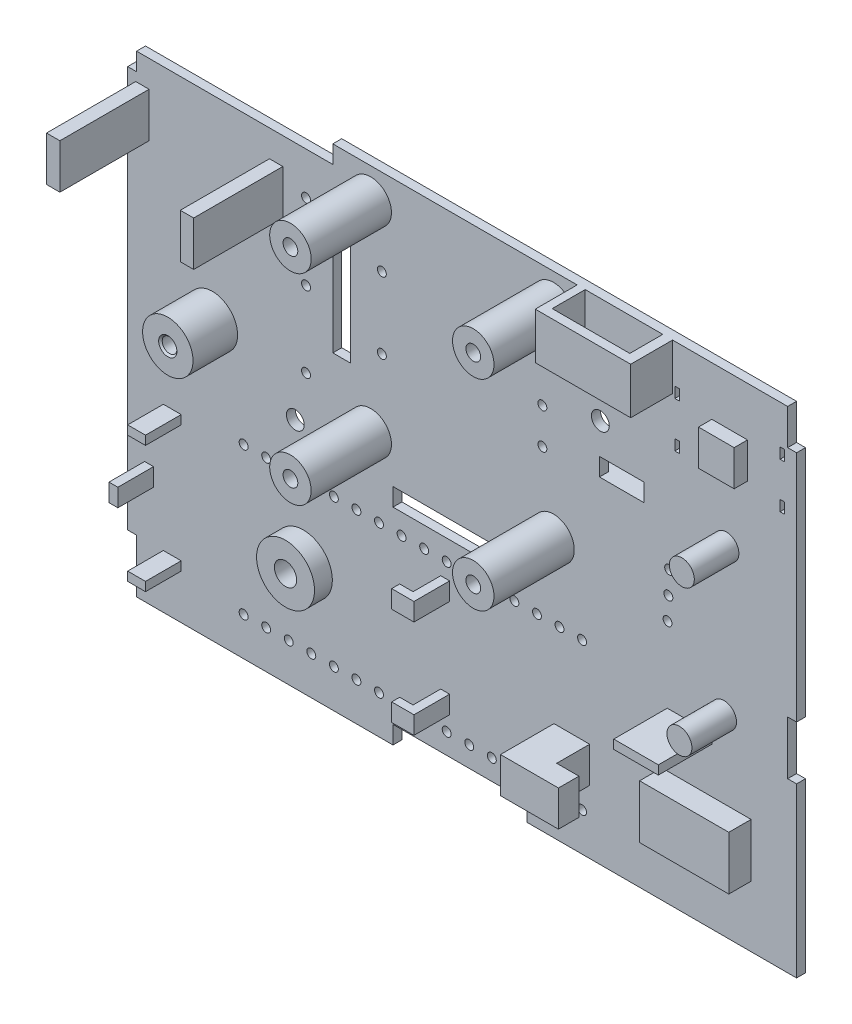
from build123d import *

# Parameters (mm, degrees)
SKETCH_1_W             = 75
SKETCH_1_H             = 55
EXTRUDE_1_DEPTH        = 1
SKETCH_2_W             = 9.7
SKETCH_2_H             = 1.5
EXTRUDE_2_DEPTH        = 7.1
CUT_EXTRUDE_1_REACH    = 20.9
SKETCH_4_W             = 1
SKETCH_4_H             = 1
CUT_EXTRUDE_2_REACH    = 3
SKETCH_5_W             = 5
SKETCH_5_H             = 2
DH11_1_START           = -1
SKETCH_9_R             = 2.825
SKETCH_9_R_2           = 0.825
DH11_1_DEPTH           = 5
SKETCH_36_W            = 1.5
SKETCH_36_H            = 5
DH11_11_DEPTH          = 10
HD11_3_SIZE            = 0.2
SKETCH_13_W            = 0.5
SKETCH_13_H            = 1.2
CUT_EXTRUDE_3_DEPTH    = 1
SKETCH_35_W            = 4
SKETCH_35_H            = 4
EXTRUDE_10_DEPTH       = 2.5
EXTRUDE_START          = -1
SKETCH_18_R            = 3.25
SKETCH_18_R_2          = 1.25
EXTRUDE_9_DEPTH        = 2
SKETCH_38_W            = 1
SKETCH_38_H            = 2
SKETCH_38_W_2          = 2
SKETCH_38_H_2          = 1
EXTRUDE_12_DEPTH       = 4
SKETCH_20_W            = 10.7
SKETCH_20_H            = 5.2
EXTRUDE_6_DEPTH        = 4.7
SKETCH_37_W            = 8.7
SKETCH_37_H            = 3.7
CUT_EXTRUDE_1_10_DEPTH = 4
SKETCH_34_W            = 0.7
SKETCH_34_H            = 0.5
CUT_EXTRUDE_10_DEPTH   = 1.2
SKETCH_28_R            = 1.4
EXTRUDE_11_DEPTH       = 5
SKETCH_19_R            = 0.5
CUT_EXTRUDE_4_DEPTH    = 1
SKETCH_30_W            = 1
SKETCH_30_H            = 4
SKETCH_30_H_2          = 6
CUT_EXTRUDE_9_DEPTH    = 1
SKETCH_33_R            = 2.325
SKETCH_33_R_2          = 0.825
EXTRUDE_10_2_DEPTH     = 9
EXTRUDE_10_2_2_DEPTH   = 9
EXTRUDE_10_2_3_DEPTH   = 9
EXTRUDE_10_2_4_DEPTH   = 9
SKETCH_39_W            = 4
SKETCH_39_H            = 4
SKETCH_39_W_2          = 5
SKETCH_39_H_2          = 1
EXTRUDE_2_2_DEPTH      = 6
SKETCH_40_W            = 10
SKETCH_40_H            = 6
EXTRUDE_3_DEPTH        = 2.5
SKETCH_41_R            = 0.5
CUT_EXTRUDE_10_2_DEPTH = 1
SKETCH_42_R            = 1
CUT_EXTRUDE_11_DEPTH   = 1
SKETCH_43_W            = 15
SKETCH_43_H            = 2
SKETCH_43_W_2          = 2
SKETCH_43_H_2          = 13.9
SKETCH_43_W_3          = 22
CUT_EXTRUDE_1_2_DEPTH  = 1
SKETCH_44_R            = 0.5
CUT_EXTRUDE_1_3_DEPTH  = 1
SKETCH_45_W            = 1.5
SKETCH_45_H            = 3
SKETCH_45_W_2          = 5
SKETCH_45_H_2          = 1.5
ESP32_2_DEPTH          = 1
SKETCH_46_W            = 2.3
SKETCH_46_H            = 4
EXTRUDE_3_2_DEPTH      = 2.5
SKETCH_47_W            = 0.9
SKETCH_47_H            = 2
EXTRUDE_2_3_DEPTH      = 1.5
SKETCH_48_W            = 9.7
SKETCH_48_H            = 7.1
EXTRUDE_2_4_DEPTH      = 3
SKETCH_49_W            = 7.7
SKETCH_49_H            = 6.1
CUT_EXTRUDE_1_4_DEPTH  = 3


with BuildPart() as part:
    # 草图1 → 凸台-拉伸1 (new body)
    with BuildSketch(Plane.XY):
        Rectangle(SKETCH_1_W, SKETCH_1_H)
    extrude(amount=EXTRUDE_1_DEPTH)

    # 草图2 → Extrude 2 (add)
    with BuildSketch(Plane(origin=(0, 0, 0), x_dir=(-1, 0, 0), z_dir=(0, 0, -1))):
        with Locations((-17.897659093, 9.35)):
            Rectangle(SKETCH_2_W, SKETCH_2_H)
    extrude(amount=EXTRUDE_2_DEPTH)

    # 草图4 → Cut-Extrude 1 (cut, up to next)
    with BuildSketch(Plane.XZ.offset(-8.6), mode=Mode.PRIVATE) as cut_extrude_1_sk1:
        with Locations((16.697659093, -3.3)):
            Rectangle(SKETCH_4_W, SKETCH_4_H)
    cut_extrude_1_tool1 = extrude(cut_extrude_1_sk1.sketch, amount=-CUT_EXTRUDE_1_REACH, mode=Mode.PRIVATE) & part.part
    add(cut_extrude_1_tool1.solids().sort_by_distance((16.697659, 8.6, -3.3))[0], mode=Mode.SUBTRACT)
    # 草图4 → Cut-Extrude 1 (cut, up to next)
    with BuildSketch(Plane.XZ.offset(-8.6), mode=Mode.PRIVATE) as cut_extrude_1_sk2:
        with Locations((19.097659093, -3.3)):
            Rectangle(SKETCH_4_W, SKETCH_4_H)
    cut_extrude_1_tool2 = extrude(cut_extrude_1_sk2.sketch, amount=-CUT_EXTRUDE_1_REACH, mode=Mode.PRIVATE) & part.part
    add(cut_extrude_1_tool2.solids().sort_by_distance((19.097659, 8.6, -3.3))[0], mode=Mode.SUBTRACT)

    # 草图5 → 电源线切除-拉伸2 (cut, up to next)
    with BuildSketch(Plane(origin=(0, 0, 0), x_dir=(-1, 0, 0), z_dir=(0, 0, -1)), mode=Mode.PRIVATE) as cut_extrude_2_sk1:
        with Locations((-17.897659093, 11.1)):
            Rectangle(SKETCH_5_W, SKETCH_5_H)
    cut_extrude_2_tool1 = extrude(cut_extrude_2_sk1.sketch, amount=-CUT_EXTRUDE_2_REACH, mode=Mode.PRIVATE) & part.part
    add(cut_extrude_2_tool1.solids().sort_by_distance((17.897659, 11.1, 0))[0], mode=Mode.SUBTRACT)

    # 草图36 → DH11凸台-拉伸11 (add)
    with BuildSketch(Plane.XY.offset(1)):
        with Locations((-20.85, 20)):
            Rectangle(SKETCH_36_W, SKETCH_36_H)
        with Locations((-35.85, 20)):
            Rectangle(SKETCH_36_W, SKETCH_36_H)
    extrude(amount=DH11_11_DEPTH)

    # 草图13 → 按键切除-拉伸3 (cut)
    with BuildSketch(Plane(origin=(0, 0, 0), x_dir=(-1, 0, 0), z_dir=(0, 0, -1))):
        with Locations((-24.1, 22.55)):
            Rectangle(SKETCH_13_W, SKETCH_13_H)
        with Locations((-35.9, 22.55)):
            Rectangle(SKETCH_13_W, SKETCH_13_H)
        with Locations((-24.1, 17.45)):
            Rectangle(SKETCH_13_W, SKETCH_13_H)
        with Locations((-35.9, 17.45)):
            Rectangle(SKETCH_13_W, SKETCH_13_H)
    extrude(amount=-CUT_EXTRUDE_3_DEPTH, mode=Mode.SUBTRACT)

    # 草图35 → Extrude 10 (add)
    with BuildSketch(Plane(origin=(0, 0, 0), x_dir=(-1, 0, 0), z_dir=(0, 0, -1))):
        with Locations((-30, 20)):
            Rectangle(SKETCH_35_W, SKETCH_35_H)
    extrude(amount=-EXTRUDE_10_DEPTH)

    # 草图38 → 蜂鸣凸台-拉伸12 (add)
    with BuildSketch(Plane.XY.offset(1)):
        with Locations((-1.9, -9.388237088)):
            Rectangle(SKETCH_38_W, SKETCH_38_H)
        with Locations((-1.9, -20.388237088)):
            Rectangle(SKETCH_38_W, SKETCH_38_H)
        with Locations((-32.5, -7.788237088)):
            Rectangle(SKETCH_38_W_2, SKETCH_38_H_2)
        with Locations((-32.5, -21.988237088)):
            Rectangle(SKETCH_38_W_2, SKETCH_38_H_2)
        with Locations((-35.1, -14.895044034)):
            Rectangle(SKETCH_38_W, SKETCH_38_H)
    extrude(amount=EXTRUDE_12_DEPTH)

    # 草图20 → 开关凸台-拉伸6 (add)
    with BuildSketch(Plane(origin=(0, 0, 0), x_dir=(-1, 0, 0), z_dir=(0, 0, -1)).offset(EXTRUDE_START)):
        with Locations((-18.25, 24.9)):
            Rectangle(SKETCH_20_W, SKETCH_20_H)
    extrude(amount=-EXTRUDE_6_DEPTH)

    # 草图37 → 开关1切除-拉伸10 (cut)
    with BuildSketch(Plane(origin=(0, 27.5, 0), x_dir=(1, 0, 0), z_dir=(0, 1, 0))):
        with Locations((18.15, -2.85)):
            Rectangle(SKETCH_37_W, SKETCH_37_H)
    extrude(amount=-CUT_EXTRUDE_1_10_DEPTH, mode=Mode.SUBTRACT)

    # 草图34 → Cut-Extrude 10 (cut)
    with BuildSketch(Plane.XZ.offset(-22.3)):
        with Locations((15.65, 2.75)):
            Rectangle(SKETCH_34_W, SKETCH_34_H)
        with Locations((18.15, 2.75)):
            Rectangle(SKETCH_34_W, SKETCH_34_H)
        with Locations((20.65, 2.75)):
            Rectangle(SKETCH_34_W, SKETCH_34_H)
    extrude(amount=-CUT_EXTRUDE_10_DEPTH, mode=Mode.SUBTRACT)

    # 草图28 → 红外凸台-拉伸11 (add)
    with BuildSketch(Plane.XY.offset(1)):
        with Locations((29.635597936, 10.476243092)):
            Circle(SKETCH_28_R)
        with Locations((29.364402064, -6.021528054)):
            Circle(SKETCH_28_R)
    extrude(amount=EXTRUDE_11_DEPTH)

    # 草图19 → 红外切除-拉伸4 (cut)
    with BuildSketch(Plane(origin=(0, 0, 0), x_dir=(-1, 0, 0), z_dir=(0, 0, -1))):
        with Locations((-23.032469059, -0.080921967)):
            Circle(SKETCH_19_R)
        with Locations((-23.12406249, 2.457426048)):
            Circle(SKETCH_19_R)
        with Locations((-23.215655921, 4.995774062)):
            Circle(SKETCH_19_R)
    extrude(amount=-CUT_EXTRUDE_4_DEPTH, mode=Mode.SUBTRACT)

    # 草图30 → 螺丝孔切除-拉伸9 (cut)
    with BuildSketch(Plane(origin=(0, 0, 0), x_dir=(-1, 0, 0), z_dir=(0, 0, -1))):
        with Locations((37, 25.5)):
            Rectangle(SKETCH_30_W, SKETCH_30_H)
        with Locations((37, -24.5)):
            Rectangle(SKETCH_30_W, SKETCH_30_H_2)
        with Locations((-37, -5.65)):
            Rectangle(SKETCH_30_W, SKETCH_30_H_2)
        with Locations((-37, 25.5)):
            Rectangle(SKETCH_30_W, SKETCH_30_H)
    extrude(amount=-CUT_EXTRUDE_9_DEPTH, mode=Mode.SUBTRACT)

    # 草图39 → Extrude 2 2 (add)
    with BuildSketch(Plane.XY.offset(1)):
        with Locations((12.3, -18.4)):
            Rectangle(SKETCH_39_W, SKETCH_39_H)
        with Locations((25.5, -9.05)):
            Rectangle(SKETCH_39_W_2, SKETCH_39_H_2)
    extrude(amount=EXTRUDE_2_2_DEPTH)

    # 草图40 → Extrude 3 (add)
    with BuildSketch(Plane.XY.offset(1)):
        with Locations((27.4, -17.65)):
            Rectangle(SKETCH_40_W, SKETCH_40_H)
    extrude(amount=EXTRUDE_3_DEPTH)

    # 草图41 → Cut-Extrude 10 2 (cut)
    with BuildSketch(Plane.XY.offset(1)):
        with Locations((-24.5, -23.2)):
            Circle(SKETCH_41_R)
        with Locations((-21.97, -23.2)):
            Circle(SKETCH_41_R)
        with Locations((-19.44, -23.2)):
            Circle(SKETCH_41_R)
        with Locations((-16.91, -23.2)):
            Circle(SKETCH_41_R)
        with Locations((-14.38, -23.2)):
            Circle(SKETCH_41_R)
        with Locations((-11.85, -23.2)):
            Circle(SKETCH_41_R)
        with Locations((-9.32, -23.2)):
            Circle(SKETCH_41_R)
        with Locations((-6.79, -23.2)):
            Circle(SKETCH_41_R)
        with Locations((-4.26, -23.2)):
            Circle(SKETCH_41_R)
        with Locations((-1.73, -23.2)):
            Circle(SKETCH_41_R)
        with Locations((0.8, -23.2)):
            Circle(SKETCH_41_R)
        with Locations((3.33, -23.2)):
            Circle(SKETCH_41_R)
        with Locations((5.86, -23.2)):
            Circle(SKETCH_41_R)
        with Locations((8.39, -23.2)):
            Circle(SKETCH_41_R)
        with Locations((10.92, -23.2)):
            Circle(SKETCH_41_R)
        with Locations((13.45, -23.2)):
            Circle(SKETCH_41_R)
        with Locations((13.45, -6.7)):
            Circle(SKETCH_41_R)
        with Locations((10.92, -6.7)):
            Circle(SKETCH_41_R)
        with Locations((8.39, -6.7)):
            Circle(SKETCH_41_R)
        with Locations((5.86, -6.7)):
            Circle(SKETCH_41_R)
        with Locations((3.33, -6.7)):
            Circle(SKETCH_41_R)
        with Locations((0.8, -6.7)):
            Circle(SKETCH_41_R)
        with Locations((-1.73, -6.7)):
            Circle(SKETCH_41_R)
        with Locations((-4.26, -6.7)):
            Circle(SKETCH_41_R)
        with Locations((-6.79, -6.7)):
            Circle(SKETCH_41_R)
        with Locations((-9.32, -6.7)):
            Circle(SKETCH_41_R)
        with Locations((-11.85, -6.7)):
            Circle(SKETCH_41_R)
        with Locations((-14.38, -6.7)):
            Circle(SKETCH_41_R)
        with Locations((-16.91, -6.7)):
            Circle(SKETCH_41_R)
        with Locations((-19.44, -6.7)):
            Circle(SKETCH_41_R)
        with Locations((-21.97, -6.7)):
            Circle(SKETCH_41_R)
        with Locations((-24.5, -6.7)):
            Circle(SKETCH_41_R)
        with Locations((9, 9.85)):
            Circle(SKETCH_41_R)
        with Locations((9, 13.85)):
            Circle(SKETCH_41_R)
        with Locations((-9, 17.85)):
            Circle(SKETCH_41_R)
        with Locations((-9, 9.85)):
            Circle(SKETCH_41_R)
    extrude(amount=-CUT_EXTRUDE_10_2_DEPTH, mode=Mode.SUBTRACT)

    # 草图42 → 固定孔切除-拉伸11 (cut)
    with BuildSketch(Plane(origin=(0, 0, 0), x_dir=(-1, 0, 0), z_dir=(0, 0, -1))):
        with Locations((-15.5, 15.6)):
            Circle(SKETCH_42_R)
        with Locations((18.7, -1.4)):
            Circle(SKETCH_42_R)
    extrude(amount=-CUT_EXTRUDE_11_DEPTH, mode=Mode.SUBTRACT)

    # 草图43 → Cut-Extrude 1 2 (cut)
    with BuildSketch(Plane(origin=(0, 0, 0), x_dir=(-1, 0, 0), z_dir=(0, 0, -1))):
        with Locations((0.25, -3.4)):
            Rectangle(SKETCH_43_W, SKETCH_43_H)
        with Locations((0.25, -26.5)):
            Rectangle(SKETCH_43_W, SKETCH_43_H)
        with Locations((13.5, 14.15)):
            Rectangle(SKETCH_43_W_2, SKETCH_43_H_2)
        with Locations((25.5, 26.5)):
            Rectangle(SKETCH_43_W_3, SKETCH_43_H)
    extrude(amount=-CUT_EXTRUDE_1_2_DEPTH, mode=Mode.SUBTRACT)

    # 草图44 → Cut-Extrude 1 3 (cut)
    with BuildSketch(Plane(origin=(0, 0, 0), x_dir=(-1, 0, 0), z_dir=(0, 0, -1))):
        with Locations((17.5, 20.75)):
            Circle(SKETCH_44_R)
        with Locations((17.5, 12.25)):
            Circle(SKETCH_44_R)
        with Locations((17.5, 3.75)):
            Circle(SKETCH_44_R)
    extrude(amount=-CUT_EXTRUDE_1_3_DEPTH, mode=Mode.SUBTRACT)

    # 草图45 → ESP32固定凸台-拉伸2 (add)
    with BuildSketch(Plane(origin=(0, 0, 0), x_dir=(-1, 0, 0), z_dir=(0, 0, -1))):
        with Locations((-20.85, -15)):
            Rectangle(SKETCH_45_W, SKETCH_45_H)
        with Locations((-15.5, -3.55)):
            Rectangle(SKETCH_45_W_2, SKETCH_45_H_2)
        with Locations((11.5, -3.55)):
            Rectangle(SKETCH_45_W_2, SKETCH_45_H_2)
        with Locations((11.5, -26.35)):
            Rectangle(SKETCH_45_W_2, SKETCH_45_H_2)
        with Locations((-15.5, -26.35)):
            Rectangle(SKETCH_45_W_2, SKETCH_45_H_2)
    extrude(amount=ESP32_2_DEPTH)

    # 草图46 → Extrude 3 2 (add)
    with BuildSketch(Plane(origin=(14.3, 0, 0), x_dir=(0, 0, -1), z_dir=(1, 0, 0))):
        with Locations((-5.85, -18.4)):
            Rectangle(SKETCH_46_W, SKETCH_46_H)
    extrude(amount=EXTRUDE_3_2_DEPTH)

    # 草图47 → Extrude 2 3 (add)
    with BuildSketch(Plane.ZY.offset(2.4)):
        with Locations((4.55, -20.388237088)):
            Rectangle(SKETCH_47_W, SKETCH_47_H)
        with Locations((4.55, -9.388237088)):
            Rectangle(SKETCH_47_W, SKETCH_47_H)
    extrude(amount=EXTRUDE_2_3_DEPTH)

    # 草图48 → Extrude 2 4 (add)
    with BuildSketch(Plane.XZ.offset(-8.6)):
        with Locations((17.897659093, -3.55)):
            Rectangle(SKETCH_48_W, SKETCH_48_H)
    extrude(amount=EXTRUDE_2_4_DEPTH)

    # 草图49 → Cut-Extrude 1 4 (cut)
    with BuildSketch(Plane.XZ.offset(-5.6)):
        with Locations((17.897659093, -3.05)):
            Rectangle(SKETCH_49_W, SKETCH_49_H)
    extrude(amount=-CUT_EXTRUDE_1_4_DEPTH, mode=Mode.SUBTRACT)


with BuildPart() as body_2:
    # 草图9 → DH11拉伸-薄壁1 (new body)
    with BuildSketch(Plane(origin=(0, 0, 0), x_dir=(-1, 0, 0), z_dir=(0, 0, -1)).offset(DH11_1_START)):
        with Locations((28, 3.6)):
            Circle(SKETCH_9_R)
        with Locations((28, 3.6)):
            Circle(SKETCH_9_R_2, mode=Mode.SUBTRACT)
    extrude(amount=-DH11_1_DEPTH)

    # HD11倒角3
    hd11_3_edges = [body_2.edges().sort_by_distance(p)[0] for p in [
        (-27.175, 3.6, 6),
    ]]
    chamfer(hd11_3_edges, length=HD11_3_SIZE)


with BuildPart() as body_3:
    # 草图18 → 蜂鸣拉伸-薄壁9 (new body)
    with BuildSketch(Plane(origin=(0, 0, 0), x_dir=(-1, 0, 0), z_dir=(0, 0, -1)).offset(EXTRUDE_START)):
        with Locations((17.8, -14.888237088)):
            Circle(SKETCH_18_R)
        with Locations((17.8, -14.888237088)):
            Circle(SKETCH_18_R_2, mode=Mode.SUBTRACT)
    extrude(amount=-EXTRUDE_9_DEPTH)


with BuildPart() as body_4:
    # 草图33 → Extrude 10 2 (new body)
    with BuildSketch(Plane.XY.offset(1)):
        with Locations((-10.25, 24.1)):
            Circle(SKETCH_33_R)
        with Locations((-10.25, 24.1)):
            Circle(SKETCH_33_R_2, mode=Mode.SUBTRACT)
    extrude(amount=EXTRUDE_10_2_DEPTH)


with BuildPart() as body_5:
    # 草图33 → Extrude 10 2 2 (new body)
    with BuildSketch(Plane.XY.offset(1)):
        with Locations((10.25, 24.1)):
            Circle(SKETCH_33_R)
        with Locations((10.25, 24.1)):
            Circle(SKETCH_33_R_2, mode=Mode.SUBTRACT)
    extrude(amount=EXTRUDE_10_2_2_DEPTH)


with BuildPart() as body_6:
    # 草图33 → Extrude 10 2 3 (new body)
    with BuildSketch(Plane.XY.offset(1)):
        with Locations((-10.25, 1.6)):
            Circle(SKETCH_33_R)
        with Locations((-10.25, 1.6)):
            Circle(SKETCH_33_R_2, mode=Mode.SUBTRACT)
    extrude(amount=EXTRUDE_10_2_3_DEPTH)


with BuildPart() as body_7:
    # 草图33 → Extrude 10 2 4 (new body)
    with BuildSketch(Plane.XY.offset(1)):
        with Locations((10.25, 1.6)):
            Circle(SKETCH_33_R)
        with Locations((10.25, 1.6)):
            Circle(SKETCH_33_R_2, mode=Mode.SUBTRACT)
    extrude(amount=EXTRUDE_10_2_4_DEPTH)


solid = Compound([part.part, body_2.part, body_3.part, body_4.part, body_5.part, body_6.part, body_7.part])
